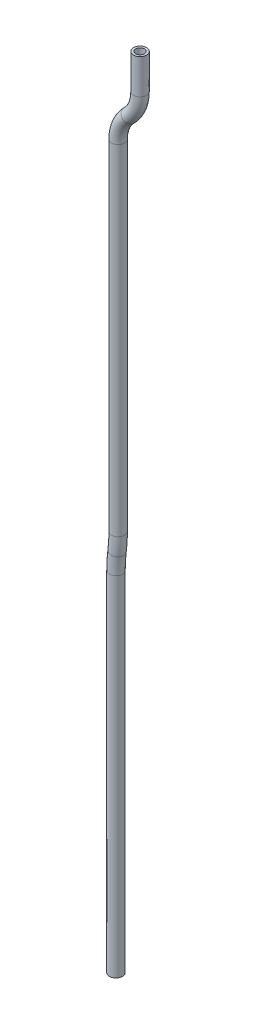
from build123d import *

# Parameters (mm, degrees)
SKETCH2_R   = 4.7625
SKETCH2_R_2 = 3.175


with BuildPart() as part:
    # Sweep1: sweep along a path in Sketch1
    with BuildLine(Plane.XY) as sweep1_path:
        Line((0, 0), (0, 254))
        ThreePointArc((0, 254), (0.198630909, 260.362390256), (0.79375, 266.7))
        ThreePointArc((0.79375, 266.7), (1.388869091, 273.037609744), (1.5875, 279.4))
        Line((1.5875, 279.4), (1.5875, 527.05))
        ThreePointArc((1.5875, 527.05), (3.663854401, 537.377471366), (9.570241337, 546.1))
        ThreePointArc((9.570241337, 546.1), (15.476628273, 554.822528634), (17.552982674, 565.15))
        Line((17.552982674, 565.15), (17.552982674, 590.55))
    # Sketch2 → Sweep1 (sweep)
    with BuildSketch(Plane(origin=(0, 0, 0), x_dir=(1, 0, 0), z_dir=(0, 1, 0))):
        Circle(SKETCH2_R)
        Circle(SKETCH2_R_2, mode=Mode.SUBTRACT)
    sweep(path=sweep1_path.line)


solid = part.part
